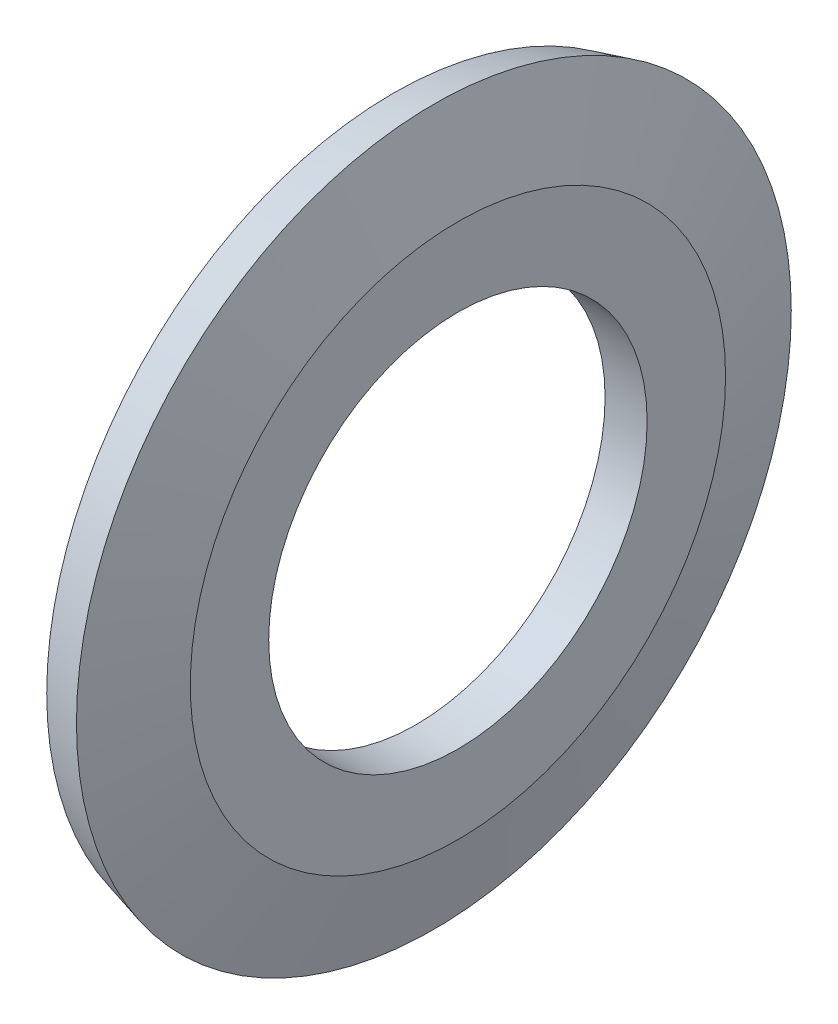
from build123d import *


with BuildPart() as part:
    # Sketch1 → Revolve1 (revolve)
    with BuildSketch(Plane.XY):
        Polygon((1, 4.5), (0, 4.5), (0, 6.233347502), (-0.537997352, 8.241180955), (0.427928474, 8.5), (1, 6.365), align=None)
    revolve(axis=Axis((1, 0, 0), (-1, 0, 0)))


solid = part.part
